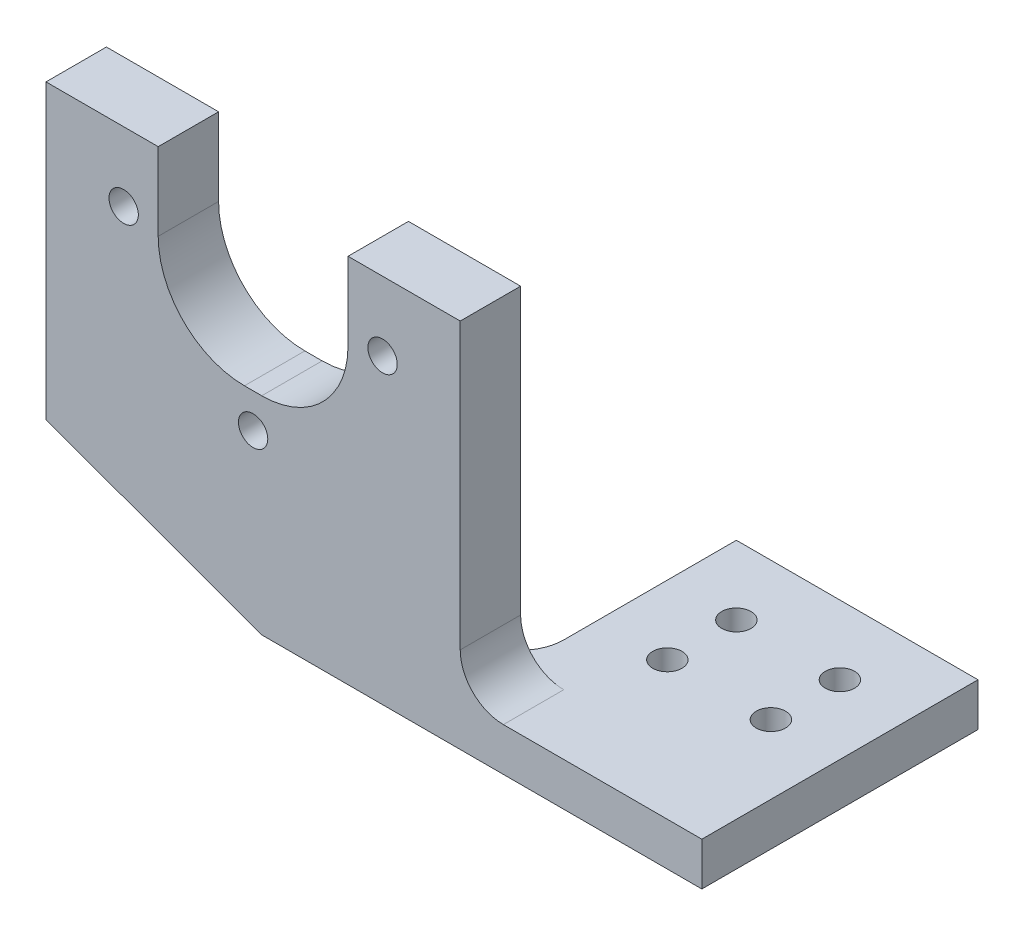
from build123d import *

# Parameters (mm, degrees)
SKETCH1_W            = 28
SKETCH1_H            = 32
BOSS_EXTRUDE1_DEPTH  = 5
M3_CLEARANCE_HOLE1_D = 3.4
BOSS_EXTRUDE2_DEPTH  = 7
FILLET1_R            = 10
FILLET2_R            = 5
FILLET3_R            = 5
M3_CLEARANCE_HOLE2_D = 3.4
CHAMFER1_SIZE        = 25
CHAMFER1_SIZE2       = 9.099255857


with BuildPart() as part:
    # Sketch1 → Boss-Extrude1 (new body)
    with BuildSketch(Plane(origin=(0, 0, 0), x_dir=(1, 0, 0), z_dir=(0, 1, 0))):
        Rectangle(SKETCH1_W, SKETCH1_H)
    extrude(amount=BOSS_EXTRUDE1_DEPTH)

    # M3 Clearance Hole1 (through all)
    with Locations(Plane(origin=(0, 5, 0), x_dir=(1, 0, 0), z_dir=(0, 1, 0))):
        with Locations((-6, 8), (6, 8), (6, 0), (-6, 0)):
            Hole(M3_CLEARANCE_HOLE1_D / 2)

    # Sketch5 → Boss-Extrude2 (add)
    with BuildSketch(Plane.XY.offset(16)):
        Polygon((-14, 0), (-62, 0), (-62, 43), (-49, 43), (-49, 24), (-27, 24), (-27, 43), (-14, 43), align=None)
    extrude(amount=-BOSS_EXTRUDE2_DEPTH)

    # Fillet1
    fillet1_edges = [part.edges().sort_by_distance(p)[0] for p in [
        (-49, 24, 12.5),
        (-27, 24, 12.5),
    ]]
    fillet(fillet1_edges, radius=FILLET1_R)

    # Fillet2
    fillet2_edges = [part.edges().sort_by_distance(p)[0] for p in [
        (-14, 5, 12.5),
    ]]
    fillet(fillet2_edges, radius=FILLET2_R)

    # Fillet3
    fillet3_edges = [part.edges().sort_by_distance(p)[0] for p in [
        (-14, 2.5, 9),
    ]]
    fillet(fillet3_edges, radius=FILLET3_R)

    # M3 Clearance Hole2 (through all)
    with Locations(Plane.XY.offset(16)):
        with Locations((-53, 35), (-23, 35), (-38, 20)):
            Hole(M3_CLEARANCE_HOLE2_D / 2)

    # Chamfer1
    chamfer1_edges = [part.edges().sort_by_distance(p)[0] for p in [
        (-62, 0, 12.5),
    ]]
    chamfer1_side = [part.faces().sort_by_distance(p)[0] for p in [
        (-10.698240226, 0, 3.653109537),
    ]]
    chamfer(chamfer1_edges, length=CHAMFER1_SIZE, length2=CHAMFER1_SIZE2, reference=chamfer1_side[0])


solid = part.part
